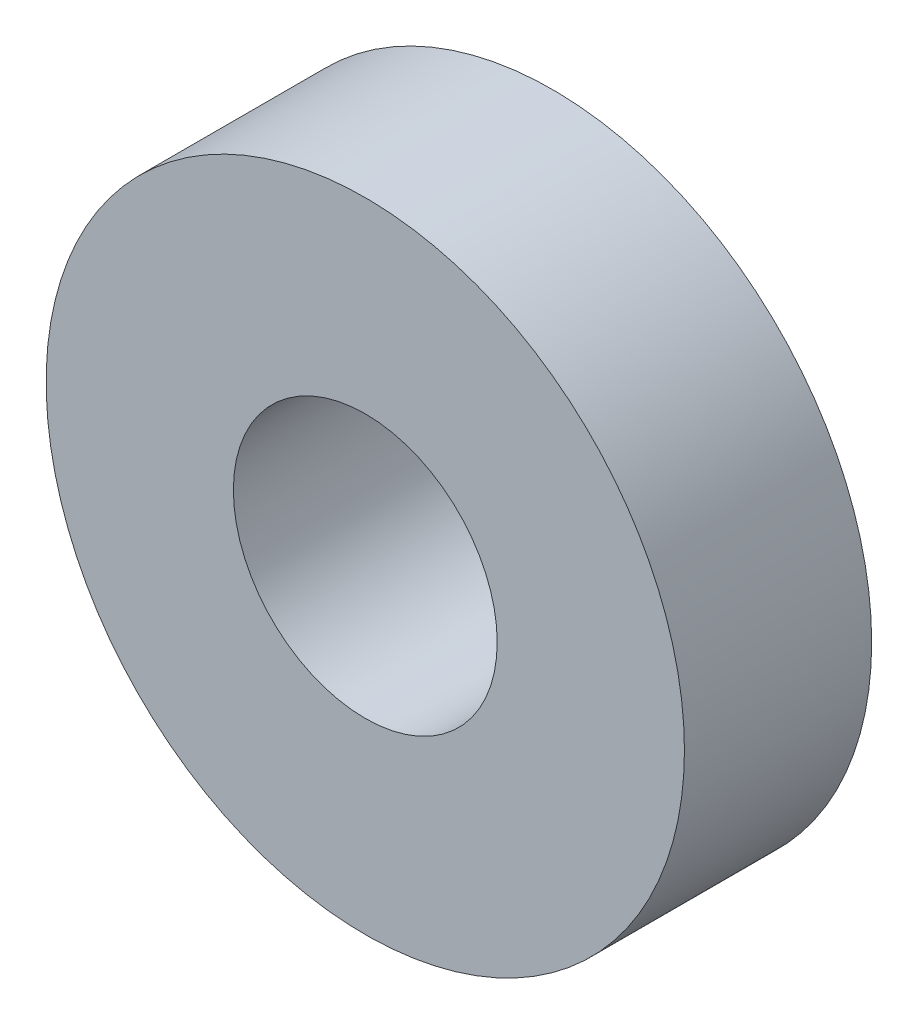
from build123d import *

# Parameters (mm, degrees)
SKETCH1_W = 5.588
SKETCH1_H = 5.588


with BuildPart() as part:
    # Sketch1 → Revolve1 (revolve)
    with BuildSketch(Plane(origin=(0, 0, 0), x_dir=(0, 0, -1), z_dir=(1, 0, 0))):
        with Locations((2.794, 6.731)):
            Rectangle(SKETCH1_W, SKETCH1_H)
    revolve(axis=Axis((0, 0, -5.588), (0, 0, 1)))


solid = part.part
